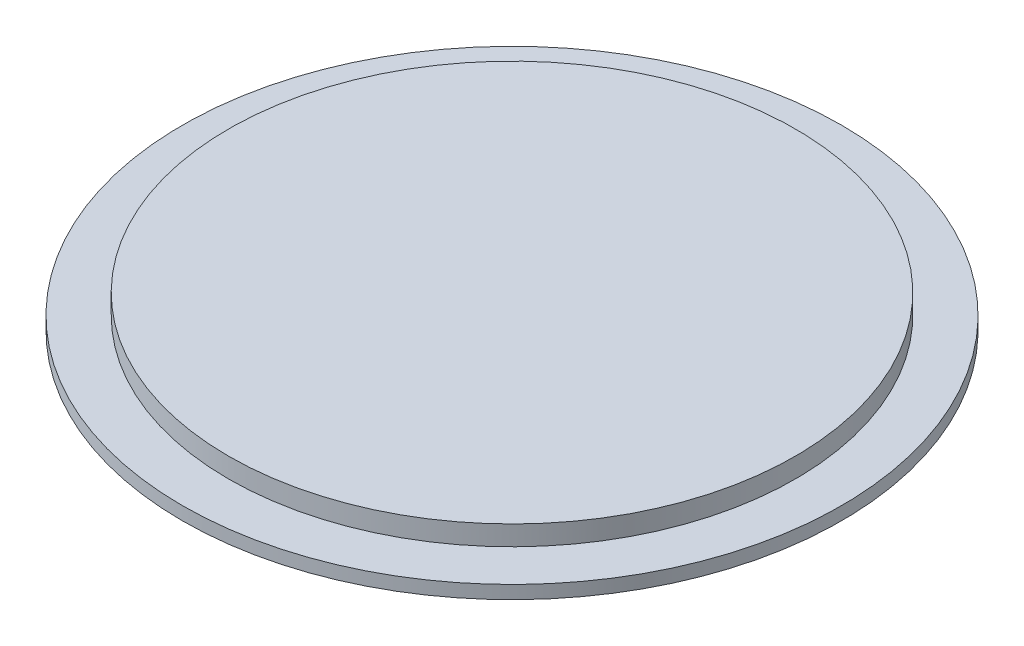
from build123d import *

# Parameters (mm, degrees)
SKETCH1_R           = 25
BOSS_EXTRUDE1_DEPTH = 1
SKETCH2_R           = 21.5
BOSS_EXTRUDE2_DEPTH = 1.5


with BuildPart() as part:
    # Sketch1 → Boss-Extrude1 (new body)
    with BuildSketch(Plane(origin=(0, 0, 0), x_dir=(1, 0, 0), z_dir=(0, 1, 0))):
        Circle(SKETCH1_R)
    extrude(amount=BOSS_EXTRUDE1_DEPTH)

    # Sketch2 → Boss-Extrude2 (add)
    with BuildSketch(Plane(origin=(0, 1, 0), x_dir=(1, 0, 0), z_dir=(0, 1, 0))):
        Circle(SKETCH2_R)
    extrude(amount=BOSS_EXTRUDE2_DEPTH)


solid = part.part
